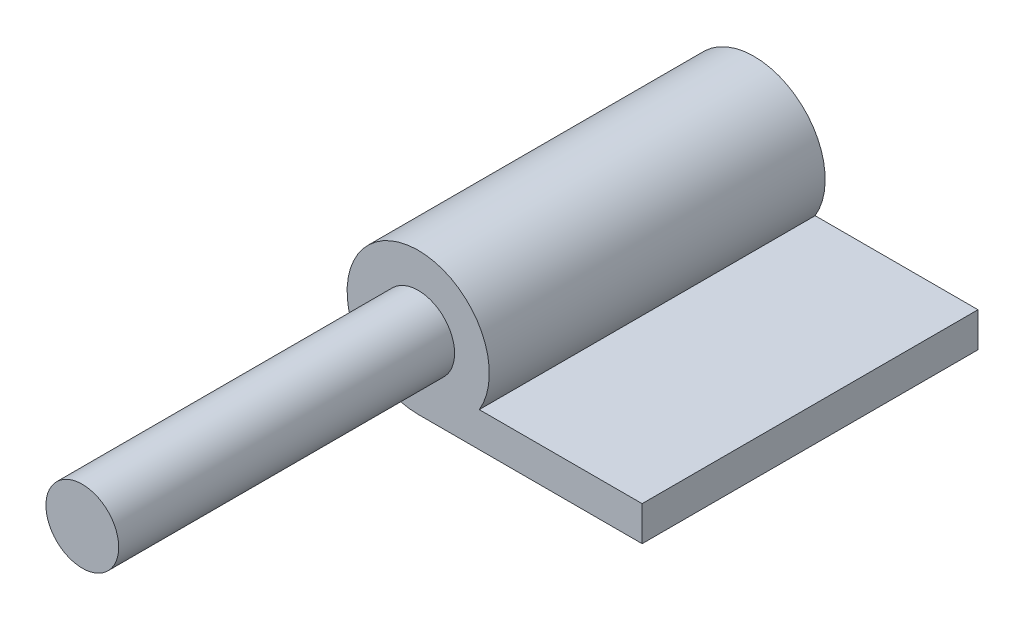
from build123d import *

# Parameters (mm, degrees)
ESBO_O1_R                = 6.35
RESSALTO_EXTRUS_O1_DEPTH = 15
ESBO_O2_W                = 20
ESBO_O2_H                = 3.1
RESSALTO_EXTRUS_O2_DEPTH = 30
ESBO_O1_3_R              = 3.25
RESSALTO_EXTRUS_O3_DEPTH = 45


with BuildPart() as part:
    # Esboço1 → Ressalto-extrusão1 (new, symmetric)
    with BuildSketch(Plane.XY):
        Circle(ESBO_O1_R)
    extrude(amount=RESSALTO_EXTRUS_O1_DEPTH, both=True)

    # Esboço2 → Ressalto-extrusão2 (add)
    with BuildSketch(Plane.XY.offset(15)):
        with Locations((10, -4.8)):
            Rectangle(ESBO_O2_W, ESBO_O2_H)
    extrude(amount=-RESSALTO_EXTRUS_O2_DEPTH)

    # Esboço1<3> → Ressalto-extrusão3 (add)
    with BuildSketch(Plane.XY):
        Circle(ESBO_O1_3_R)
    extrude(amount=RESSALTO_EXTRUS_O3_DEPTH)


solid = part.part
